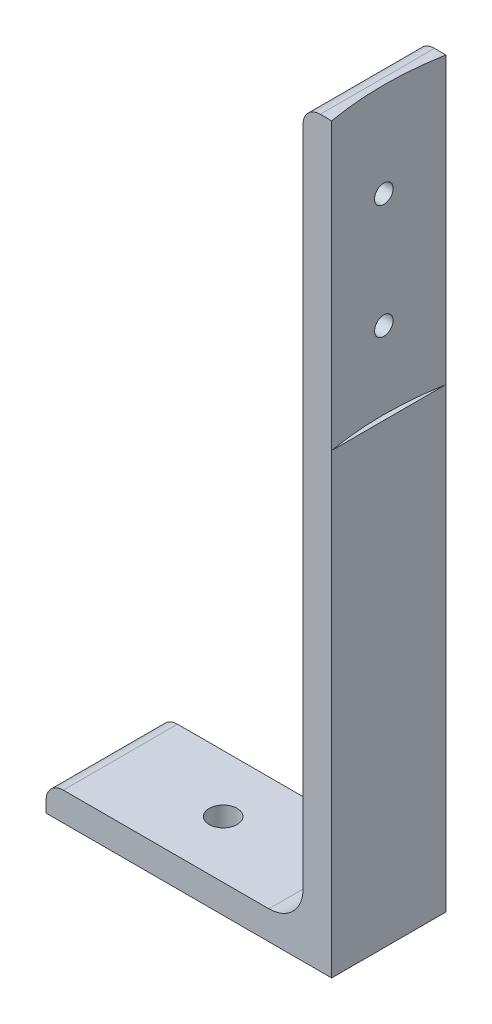
from build123d import *

# Parameters (mm, degrees)
BOSS_EXTRUDE1_DEPTH = 10
CUT_EXTRUDE1_DEPTH  = 50
SKETCH3_R           = 1.625
CUT_EXTRUDE2_DEPTH  = 6
SKETCH8_R           = 2.45
CUT_EXTRUDE3_DEPTH  = 6


with BuildPart() as part:
    # Sketch1 → Boss-Extrude1 (new body, symmetric)
    with BuildSketch(Plane.XY):
        with BuildLine():
            Line((0, 0), (0, 130))
            Line((0, 130), (-2, 130))
            ThreePointArc((-2, 130), (-4.121320344, 129.121320344), (-5, 127))
            Line((-5, 127), (-5, 11))
            ThreePointArc((-5, 11), (-6.757359313, 6.757359313), (-11, 5))
            Line((-11, 5), (-47, 5))
            ThreePointArc((-47, 5), (-49.121320344, 4.121320344), (-50, 2))
            Line((-50, 2), (-50, 0))
            Line((-50, 0), (0, 0))
        make_face()
    extrude(amount=BOSS_EXTRUDE1_DEPTH, both=True)

    # Sketch2 → Cut-Extrude1 (cut)
    with BuildSketch(Plane(origin=(0, 130, 0), x_dir=(1, 0, 0), z_dir=(0, 1, 0))):
        with BuildLine():
            ThreePointArc((0, 10), (-0.884048614, 0), (0, -10))
            Line((0, -10), (0, 10))
        make_face()
        with BuildLine():
            Line((0, 10), (0, -10))
            ThreePointArc((0, -10), (61.135451908, -56.7785577), (113.115951386, 0))
            ThreePointArc((113.115951386, 0), (61.135451908, 56.7785577), (0, 10))
        make_face()
    extrude(amount=-CUT_EXTRUDE1_DEPTH, mode=Mode.SUBTRACT)

    # Sketch3 → Cut-Extrude2 (cut, through all)
    with BuildSketch(Plane.ZY.offset(5)):
        with Locations((0, 93.5)):
            Circle(SKETCH3_R)
        with Locations((0, 113.5)):
            Circle(SKETCH3_R)
    extrude(amount=-CUT_EXTRUDE2_DEPTH, mode=Mode.SUBTRACT)

    # Sketch8 → Cut-Extrude3 (cut, through all)
    with BuildSketch(Plane(origin=(0, 5, 0), x_dir=(1, 0, 0), z_dir=(0, 1, 0))):
        with Locations((-29, 0)):
            Circle(SKETCH8_R)
    extrude(amount=-CUT_EXTRUDE3_DEPTH, mode=Mode.SUBTRACT)


solid = part.part
